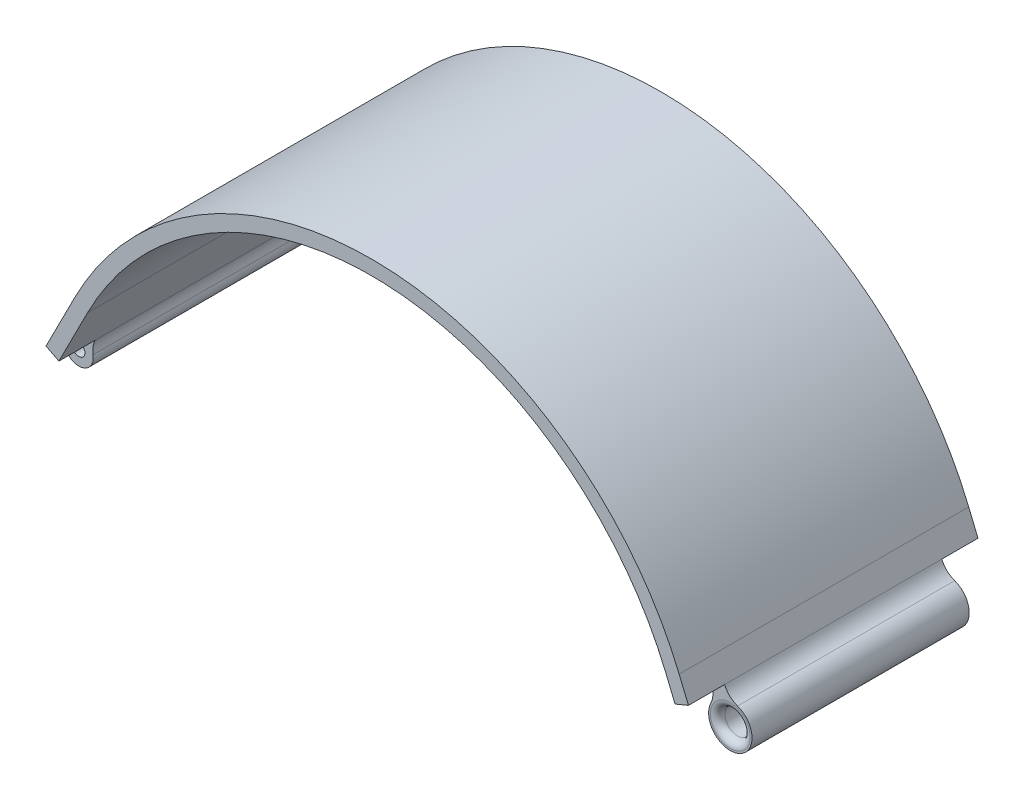
from build123d import *

# Parameters (mm, degrees)
CROQUIS1_R              = 1.7
CROQUIS1_R_2            = 3.5
SALIENTE_EXTRUIR1_DEPTH = 40
REDONDEO1_R             = 6
CORTAR_EXTRUIR1_DEPTH   = 10
REDONDEO2_R             = 2


with BuildPart() as part:
    # Croquis1 → Saliente-Extruir1 (new body, symmetric)
    with BuildSketch(Plane.XY):
        with BuildLine():
            Line((-78.419273977, 20.002017027), (-87.494309747, 2.17945476))
            ThreePointArc((-87.494309747, 2.17945476), (-92.663415431, -3.564512453), (-91.0588222, 3.994461914))
            Line((-91.0588222, 3.994461914), (-81.98378643, 21.817024181))
            ThreePointArc((-81.98378643, 21.817024181), (3.624504321, 72.000435004), (85.015988263, 15.232657976))
            Line((85.015988263, 15.232657976), (88.837814169, 5.991789686))
            ThreePointArc((88.837814169, 5.991789686), (91.444687267, -5.544520974), (85.141466854, 4.463059324))
            Line((85.141466854, 4.463059324), (81.319640948, 13.703927614))
            ThreePointArc((81.319640948, 13.703927614), (3.466917176, 68.003540423), (-78.419273977, 20.002017027))
        make_face()
        with Locations((-90.848408277, 0)):
            Circle(CROQUIS1_R, mode=Mode.SUBTRACT)
        with Locations((89.151591723, 0)):
            Circle(CROQUIS1_R_2, mode=Mode.SUBTRACT)
    extrude(amount=SALIENTE_EXTRUIR1_DEPTH, both=True)

    # Redondeo1
    redondeo1_edges = [part.edges().sort_by_distance(p)[0] for p in [
        (-87.494309747, 2.17945476, 0),
        (-91.0588222, 3.994461914, 0),
        (88.837814169, 5.991789686, 0),
        (85.141466854, 4.463059324, 0),
    ]]
    fillet(redondeo1_edges, radius=REDONDEO1_R)

    # Croquis2 → Cortar-Extruir1 (cut)
    with BuildSketch(Plane(origin=(0, 0, -40), x_dir=(-1, 0, 0), z_dir=(0, 0, -1))):
        with BuildLine():
            Line((89.908153773, 6.254272257), (86.343641319, 4.439265103))
            ThreePointArc((86.343641319, 4.439265103), (86.930196271, 2.608758116), (86.907794022, 0.686701749))
            ThreePointArc((86.907794022, 0.686701749), (92.663415431, -3.564512453), (92.611013947, 3.590713195))
            ThreePointArc((92.611013947, 3.590713195), (91.043465794, 4.703185814), (89.908153773, 6.254272257))
        make_face()
        with BuildLine():
            Line((-87.581420372, 9.029649048), (-83.885073056, 7.500918685))
            ThreePointArc((-83.885073056, 7.500918685), (-84.338136431, 5.037582192), (-83.746071903, 2.603911571))
            ThreePointArc((-83.746071903, 2.603911571), (-91.444687267, -5.544520974), (-91.138766534, 5.661372296))
            ThreePointArc((-91.138766534, 5.661372296), (-89.000661668, 6.965903123), (-87.581420372, 9.029649048))
        make_face()
    cortar_extruir1 = extrude(amount=-CORTAR_EXTRUIR1_DEPTH, mode=Mode.SUBTRACT)

    # Simetría1: Cortar-Extruir1 across plane
    add(cortar_extruir1.mirror(Plane.XY), mode=Mode.SUBTRACT)

    # Redondeo2
    redondeo2_edges = [part.edges().sort_by_distance(p)[0] for p in [
        (85.651591723, 0, 30),
        (85.651591723, 0, -30),
    ]]
    fillet(redondeo2_edges, radius=REDONDEO2_R)


solid = part.part
